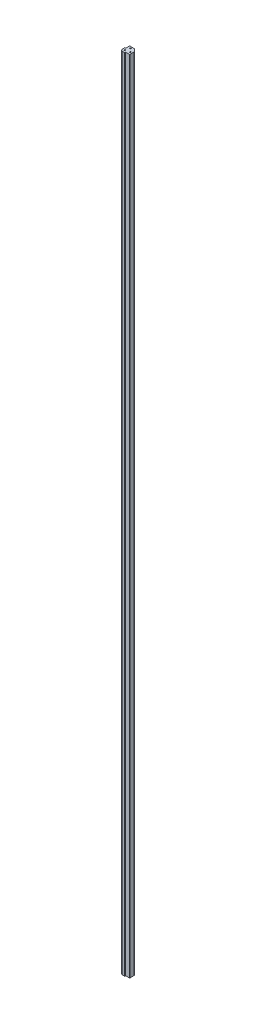
from build123d import *

# Parameters (mm, degrees)
BOSS_EXTRUDE1_DEPTH = 1828.8
THRU_HOLES_D        = 2.794


with BuildPart() as part:
    # Sketch1 → Boss-Extrude1 (new body)
    with BuildSketch(Plane(origin=(0, 0, 0), x_dir=(1, 0, 0), z_dir=(0, 1, 0))):
        with BuildLine():
            Line((-3.048, 13.208), (-3.048, 4.953))
            ThreePointArc((-3.048, 4.953), (-3.085197439, 4.863197439), (-3.175, 4.826))
            Line((-3.175, 4.826), (-4.826, 4.826))
            ThreePointArc((-4.826, 4.826), (-5.005605122, 4.751605122), (-5.08, 4.572))
            Line((-5.08, 4.572), (-5.08, 0))
            ThreePointArc((-5.08, 0), (-3.592102448, -3.592102448), (0, -5.08))
            Line((0, -5.08), (4.572, -5.08))
            ThreePointArc((4.572, -5.08), (4.751605122, -5.005605122), (4.826, -4.826))
            Line((4.826, -4.826), (4.826, -3.175))
            ThreePointArc((4.826, -3.175), (4.863197439, -3.085197439), (4.953, -3.048))
            Line((4.953, -3.048), (13.208, -3.048))
            ThreePointArc((13.208, -3.048), (13.746815367, -2.824815367), (13.97, -2.286))
            Line((13.97, -2.286), (13.97, 7.304369265))
            ThreePointArc((13.97, 7.304369265), (13.911996204, 7.595974041), (13.746815367, 7.843184633))
            Line((13.746815367, 7.843184633), (7.843184633, 13.746815367))
            ThreePointArc((7.843184633, 13.746815367), (7.595974041, 13.911996204), (7.304369265, 13.97))
            Line((7.304369265, 13.97), (-2.286, 13.97))
            ThreePointArc((-2.286, 13.97), (-2.824815367, 13.746815367), (-3.048, 13.208))
        make_face()
    extrude(amount=BOSS_EXTRUDE1_DEPTH)

    # THRU HOLES (through all)
    with Locations(Plane(origin=(0, 1828.8, 0), x_dir=(1, 0, 0), z_dir=(0, 1, 0))):
        with Locations((0, 0), (2.54, 10.16), (10.16, 2.54)):
            Hole(THRU_HOLES_D / 2)


solid = part.part
